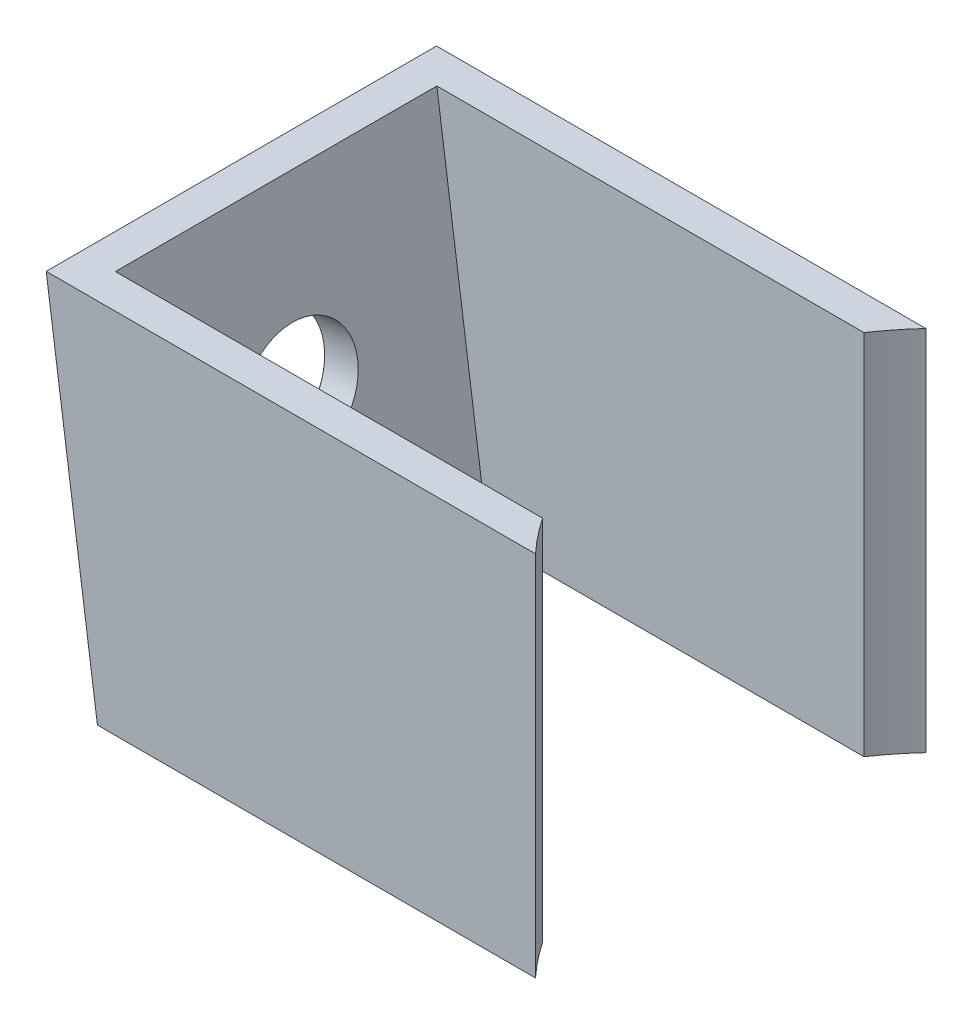
from build123d import *

# Parameters (mm, degrees)
DODANIE_WYCI_GNI_CIE1_DEPTH = 17
SKORUPA2_T                  = -1.5
SZKIC5_R                    = 12.5
WYTNIJ_WYCI_GNI_CIE1_DEPTH  = 17


with BuildPart() as part:
    # Szkic1 → Dodanie-wyciągnięcie1 (new body)
    with BuildSketch(Plane.XY):
        Polygon((-9.604686356, 8), (-30.914686356, 8), (-28.684686356, -8), (-9.604686356, -8), align=None)
    extrude(amount=DODANIE_WYCI_GNI_CIE1_DEPTH)

    # Skorupa2
    skorupa2_openings = [part.faces().sort_by_distance(p)[0] for p in [
        (-19.144686356, -8, 8.5),
        (-20.259686356, 8, 8.5),
        (-9.604686356, 0, 8.5),
    ]]
    offset(amount=SKORUPA2_T, openings=skorupa2_openings, kind=Kind.INTERSECTION)

    # Szkic3 → Pogłębienie walcowe pod M2 Śrubę z łbem stożkowym ściętym1 (revolve, cut)
    with BuildSketch(Plane(origin=(-29.834614332, 0.250604313, 8.5), x_dir=(0.138040701, -0.990426557, 0), z_dir=(0, 0, 1))):
        Polygon((0, 0), (0, 10.721032743), (1.2, 10), (1.2, 1.6), (2.5, 1.6), (2.5, 0.025), (2.525, 0), align=None)
    revolve(axis=Axis((-36.123822969, -0.625954141, 8.5), (0.990426557, 0.138040701, 0)), mode=Mode.SUBTRACT)

    # Szkic5 → Wytnij-wyciągnięcie1 (cut)
    with BuildSketch(Plane(origin=(0, 8, 0), x_dir=(1, 0, 0), z_dir=(0, 1, 0))):
        with Locations((-0.439534966, -8.5)):
            Circle(SZKIC5_R)
    extrude(amount=-WYTNIJ_WYCI_GNI_CIE1_DEPTH, mode=Mode.SUBTRACT)


solid = part.part
